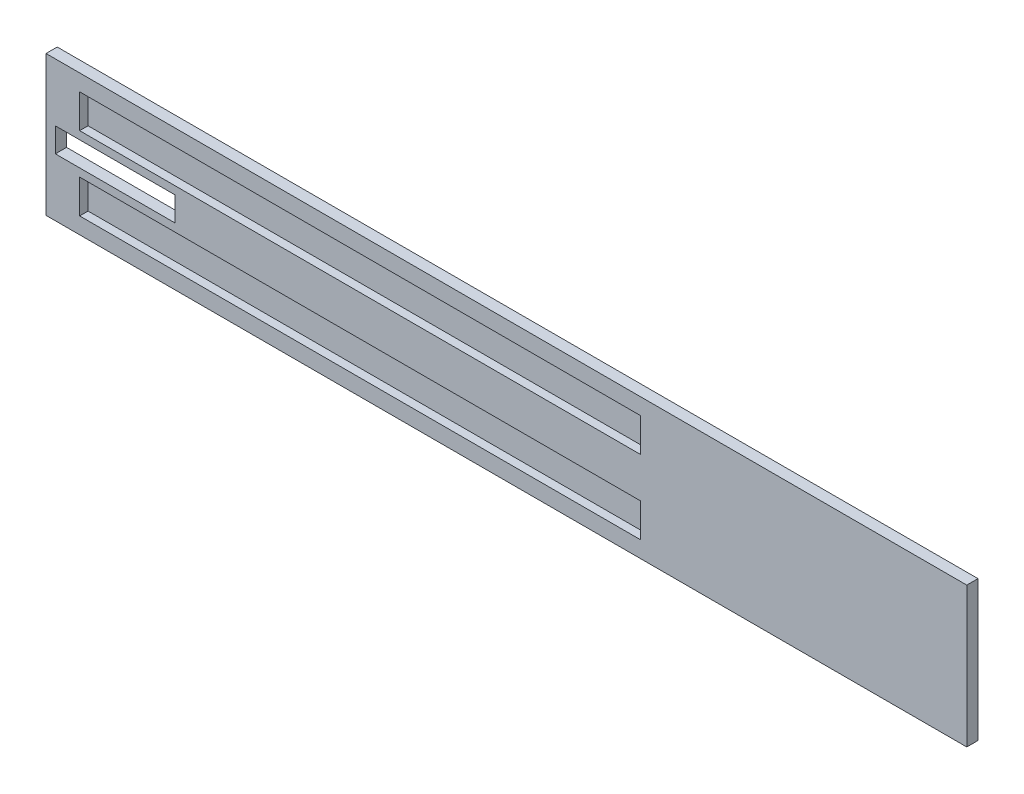
from build123d import *

# Parameters (mm, degrees)
CROQUIS1_W              = 985
CROQUIS1_H              = 150
SALIENTE_EXTRUIR1_DEPTH = 12
CROQUIS2_W              = 600
CROQUIS2_H              = 36
CORTAR_EXTRUIR1_DEPTH   = 9
CROQUIS3_W              = 128.261008082
CROQUIS3_H              = 26
CORTAR_EXTRUIR2_DEPTH   = 13


with BuildPart() as part:
    # Croquis1 → Saliente-Extruir1 (new body)
    with BuildSketch(Plane.XY):
        with Locations((492.5, 75)):
            Rectangle(CROQUIS1_W, CROQUIS1_H)
    extrude(amount=SALIENTE_EXTRUIR1_DEPTH)

    # Croquis2 → Cortar-Extruir1 (cut)
    with BuildSketch(Plane.XY.offset(12)):
        with Locations((336, 114.5)):
            Rectangle(CROQUIS2_W, CROQUIS2_H)
        with Locations((336, 35.5)):
            Rectangle(CROQUIS2_W, CROQUIS2_H)
    extrude(amount=-CORTAR_EXTRUIR1_DEPTH, mode=Mode.SUBTRACT)

    # Croquis3 → Cortar-Extruir2 (cut, through all)
    with BuildSketch(Plane.XY.offset(12)):
        with Locations((74.130504041, 75)):
            Rectangle(CROQUIS3_W, CROQUIS3_H)
    extrude(amount=-CORTAR_EXTRUIR2_DEPTH, mode=Mode.SUBTRACT)


solid = part.part
